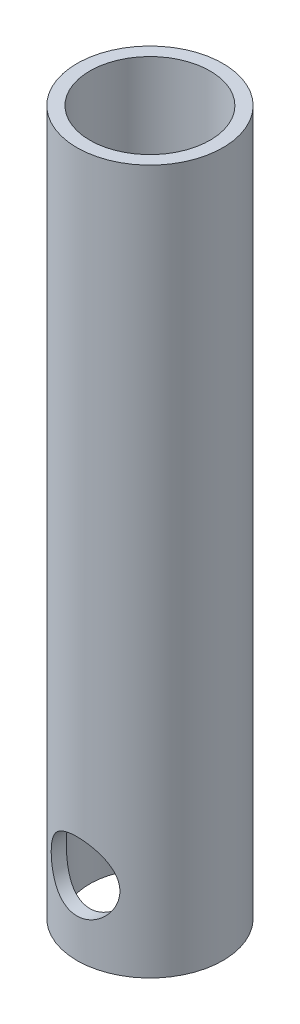
from build123d import *

# Parameters (mm, degrees)
SKETCH1_R               = 17
SKETCH1_R_2             = 14
BOSS_EXTRUDE1_DEPTH     = 164
CUT_EXTRUDE1_DEPTH      = 166.75282803
CUT_EXTRUDE1_DEPTH_BACK = 166.75282803
SKETCH2_R               = 8


with BuildPart() as part:
    # Sketch1 → Boss-Extrude1 (new body)
    with BuildSketch(Plane(origin=(0, 0, 0), x_dir=(1, 0, 0), z_dir=(0, 1, 0))):
        Circle(SKETCH1_R)
        Circle(SKETCH1_R_2, mode=Mode.SUBTRACT)
    extrude(amount=BOSS_EXTRUDE1_DEPTH)

    # Sketch2 → Cut-Extrude1 (cut, two sides: drawn at the far end of the back side and taken through both)
    with BuildSketch(Plane.XY.offset(-CUT_EXTRUDE1_DEPTH_BACK)):
        with Locations((0, 17)):
            Circle(SKETCH2_R)
    extrude(amount=CUT_EXTRUDE1_DEPTH + CUT_EXTRUDE1_DEPTH_BACK, mode=Mode.SUBTRACT)


solid = part.part
